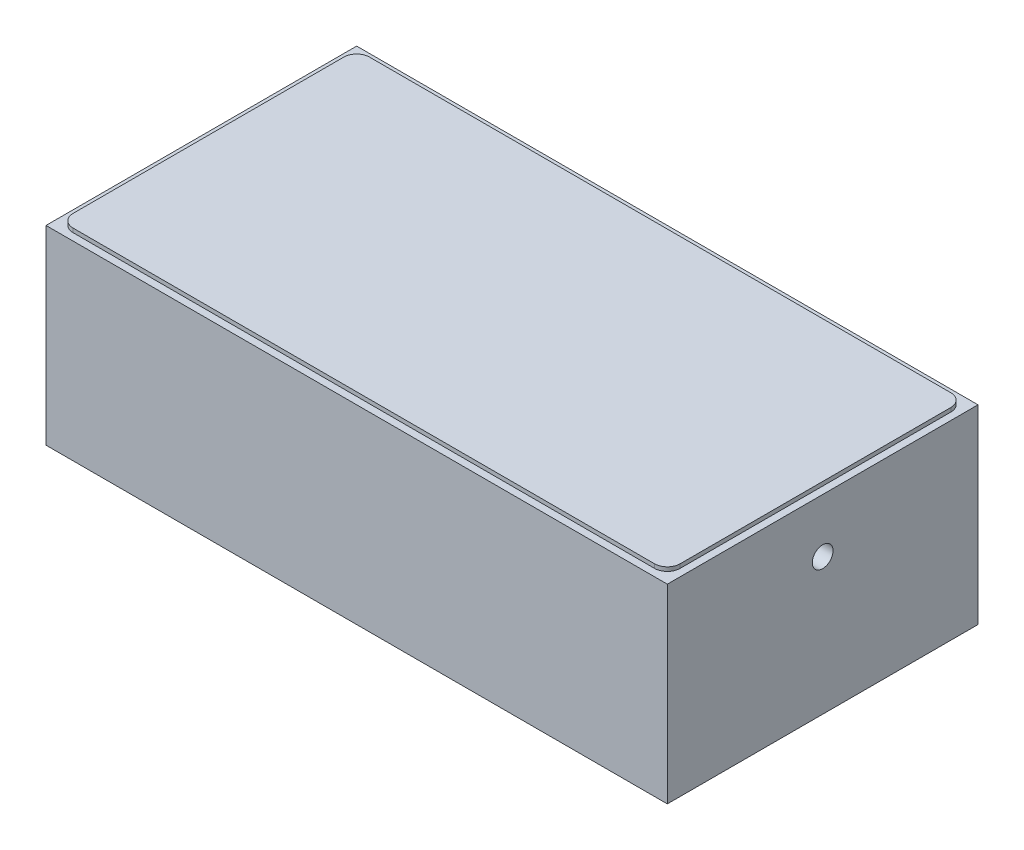
from build123d import *

# Parameters (mm, degrees)
SKETCH1_W                          = 150
SKETCH1_H                          = 75
EXTRUDE1_DEPTH                     = 48.9966
CIRPATTERN1_COUNT                  = 3
M5X0_8_TAPPED_HOLE1_D              = 4.2
M5X0_8_TAPPED_HOLE1_DEPTH          = 15.24
M5X0_8_TAPPED_HOLE1_CBORE_D        = 5
M5X0_8_TAPPED_HOLE1_CBORE_DEPTH    = 10.16
M5X0_8_TAPPED_HOLE1_TIP            = 1.2618073
F_1_4_0_25_DIAMETER_HOLE1_D        = 6.35
F_1_4_0_25_DIAMETER_HOLE1_DEPTH    = 9.652
F_1_4_0_25_DIAMETER_HOLE1_TIP      = 1.907732465
M5X0_8_TAPPED_HOLE2_D              = 4.2
M5X0_8_TAPPED_HOLE2_DEPTH          = 15.24
M5X0_8_TAPPED_HOLE2_CBORE_D        = 5
M5X0_8_TAPPED_HOLE2_CBORE_DEPTH    = 10.16
M5X0_8_TAPPED_HOLE2_TIP            = 1.2618073
F_3_16_0_1875_DIAMETER_HOLE1_D     = 4.7625
F_3_16_0_1875_DIAMETER_HOLE1_DEPTH = 12.446
CHAMFER1_SIZE                      = 3.048
EXTRUDE2_DEPTH                     = 0.96519992


with BuildPart() as part:
    # Sketch1 → Extrude1 (new body)
    with BuildSketch(Plane(origin=(0, 0, 0), x_dir=(1, 0, 0), z_dir=(0, 1, 0))):
        Rectangle(SKETCH1_W, SKETCH1_H)
    extrude(amount=EXTRUDE1_DEPTH)

    # Sketch3 → Cut-Revolve1 (revolve, cut)
    with BuildSketch(Plane.XY):
        with BuildLine():
            Line((0, -13.0148), (0, 11.9988))
            ThreePointArc((0, 11.9988), (-12.5068, -0.508), (0, -13.0148))
        make_face()
    revolve(axis=Axis((0, -13.0148, 0), (0, 1, 0)), mode=Mode.SUBTRACT)

    # Sketch4 → M3x0.5 Tapped Hole1 (revolve, cut)
    with BuildSketch(Plane(origin=(-19.05, 0, 0), x_dir=(0, 0, -1), z_dir=(1, 0, 0))):
        Polygon((0, 0), (0, 8.571684836), (1.25, 7.849997), (1.25, 0), align=None)
    m3x0_5_tapped_hole1 = revolve(axis=Axis((-19.05, -6.35, 0), (0, 1, 0)), mode=Mode.SUBTRACT)

    # CirPattern1: M3x0.5 Tapped Hole1 ×3 about axis
    cirpattern1_axis = Axis((0, 0, 0), (0, 1, 0))
    for i in range(1, CIRPATTERN1_COUNT):
        add(m3x0_5_tapped_hole1.rotate(cirpattern1_axis, i * 360 / CIRPATTERN1_COUNT), mode=Mode.SUBTRACT)

    # M5x0.8 Tapped Hole1
    with Locations(Plane(origin=(3.180539722, 0, -8.853139463), x_dir=(-1, 0, 0), z_dir=(0, -1, 0))):
        with Locations((-46.819460278, -8.853139463)):
            CounterBoreHole(M5X0_8_TAPPED_HOLE1_D / 2, M5X0_8_TAPPED_HOLE1_CBORE_D / 2, M5X0_8_TAPPED_HOLE1_CBORE_DEPTH, depth=M5X0_8_TAPPED_HOLE1_DEPTH)
            with Locations((0, 0, -(M5X0_8_TAPPED_HOLE1_DEPTH + M5X0_8_TAPPED_HOLE1_TIP / 2))):  # 118° drill point
                Cone(0, M5X0_8_TAPPED_HOLE1_D / 2, M5X0_8_TAPPED_HOLE1_TIP, mode=Mode.SUBTRACT)

    # 1_4 _0.25_ Diameter Hole1
    with Locations(Plane(origin=(7.783143684, 0, 5.786983083), x_dir=(-1, 0, 0), z_dir=(0, -1, 0))):
        with Locations((57.783143684, 5.786983083)):
            Hole(F_1_4_0_25_DIAMETER_HOLE1_D / 2, depth=F_1_4_0_25_DIAMETER_HOLE1_DEPTH)
            with Locations((0, 0, -(F_1_4_0_25_DIAMETER_HOLE1_DEPTH + F_1_4_0_25_DIAMETER_HOLE1_TIP / 2))):  # 118° drill point
                Cone(0, F_1_4_0_25_DIAMETER_HOLE1_D / 2, F_1_4_0_25_DIAMETER_HOLE1_TIP, mode=Mode.SUBTRACT)

    # M5x0.8 Tapped Hole2
    with Locations(Plane(origin=(75, -6.107751103, -10.810874371), x_dir=(0, 0, 1), z_dir=(1, 0, 0))):
        with Locations((10.810874371, -42.099551103)):
            CounterBoreHole(M5X0_8_TAPPED_HOLE2_D / 2, M5X0_8_TAPPED_HOLE2_CBORE_D / 2, M5X0_8_TAPPED_HOLE2_CBORE_DEPTH, depth=M5X0_8_TAPPED_HOLE2_DEPTH)
            with Locations((0, 0, -(M5X0_8_TAPPED_HOLE2_DEPTH + M5X0_8_TAPPED_HOLE2_TIP / 2))):  # 118° drill point
                Cone(0, M5X0_8_TAPPED_HOLE2_D / 2, M5X0_8_TAPPED_HOLE2_TIP, mode=Mode.SUBTRACT)

    # 3_16 _0.1875_ Diameter Hole1
    with Locations(Plane(origin=(-43.604904101, 0, -18.203855586), x_dir=(-1, 0, 0), z_dir=(0, -1, 0))):
        with Locations((-43.611104101, -18.188055586)):
            Hole(F_3_16_0_1875_DIAMETER_HOLE1_D / 2, depth=F_3_16_0_1875_DIAMETER_HOLE1_DEPTH)

    # Chamfer1
    chamfer1_edges = [part.edges().sort_by_distance(p)[0] for p in [
        (0, 0, -37.5),
        (75, 0, 0),
        (0, 0, 37.5),
        (-75, 0, 0),
    ]]
    chamfer(chamfer1_edges, length=CHAMFER1_SIZE)

    # Sketch14 → Extrude2 (add)
    with BuildSketch(Plane.XZ.offset(-48.9966)):
        with BuildLine():
            Line((70.1613, 35.7474), (-70.1991, 35.7474))
            ThreePointArc((-70.1991, 35.7474), (-72.381302237, 34.843502237), (-73.2852, 32.6613))
            Line((-73.2852, 32.6613), (-73.2852, -32.6929))
            ThreePointArc((-73.2852, -32.6929), (-72.381302237, -34.875102237), (-70.1991, -35.779))
            Line((-70.1991, -35.779), (70.1613, -35.779))
            ThreePointArc((70.1613, -35.779), (72.343502237, -34.875102237), (73.2474, -32.6929))
            Line((73.2474, -32.6929), (73.2474, 32.6613))
            ThreePointArc((73.2474, 32.6613), (72.343502237, 34.843502237), (70.1613, 35.7474))
        make_face()
    extrude(amount=-EXTRUDE2_DEPTH)


solid = part.part
